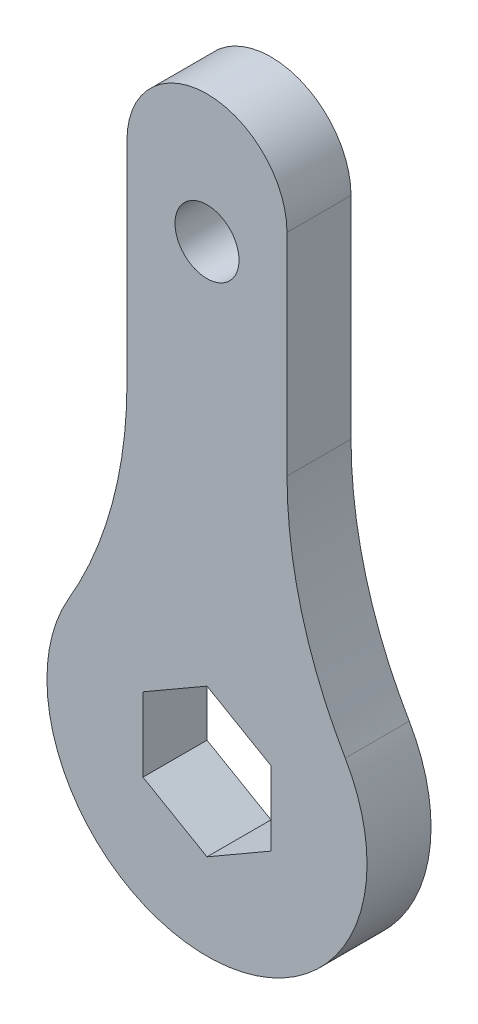
from build123d import *

# Parameters (mm, degrees)
BOSS_EXTRUDE1_DEPTH = 3
SKETCH3_R           = 1.5
CUT_EXTRUDE1_DEPTH  = 10


with BuildPart() as part:
    # Sketch1 → Boss-Extrude1 (new body)
    with BuildSketch(Plane.XY):
        with BuildLine():
            Line((-3.75, 13.863170633), (-3.75, 23.75))
            ThreePointArc((-3.75, 23.75), (0, 27.5), (3.75, 23.75))
            Line((3.75, 23.75), (3.75, 13.863170633))
            ThreePointArc((3.75, 13.863170633), (4.443854017, 8.640840954), (6.477272727, 3.780864718))
            ThreePointArc((6.477272727, 3.780864718), (0, -7.5), (-6.477272727, 3.780864718))
            ThreePointArc((-6.477272727, 3.780864718), (-4.443854017, 8.640840954), (-3.75, 13.863170633))
        make_face()
        Polygon((0, 3.464101615), (-3, 1.732050808), (-3, -1.732050808), (0, -3.464101615), (3, -1.732050808), (3, 1.732050808), align=None, mode=Mode.SUBTRACT)
    extrude(amount=BOSS_EXTRUDE1_DEPTH)

    # Sketch3 → Cut-Extrude1 (cut)
    with BuildSketch(Plane.XY.offset(3)):
        with Locations((0, 21.5)):
            Circle(SKETCH3_R)
    extrude(amount=-CUT_EXTRUDE1_DEPTH, mode=Mode.SUBTRACT)


solid = part.part
